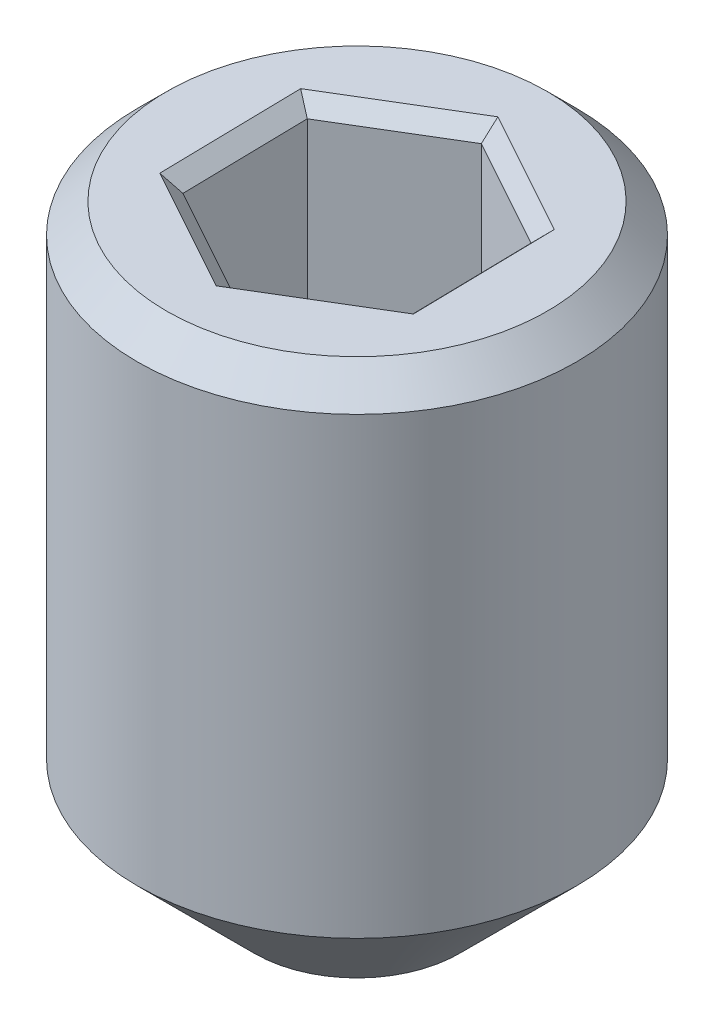
from build123d import *

# Parameters (mm, degrees)
SKETCH1_R           = 1.5
BOSS_EXTRUDE1_DEPTH = 4.1
CUT_EXTRUDE2_DEPTH  = 2
CHAMFER1_SIZE       = 0.2
CHAMFER2_SIZE       = 0.1
FILLET3_R           = 0.6
CHAMFER3_SIZE       = 0.8


with BuildPart() as part:
    # Sketch1 → Boss-Extrude1 (new body)
    with BuildSketch(Plane(origin=(0, 0, 0), x_dir=(1, 0, 0), z_dir=(0, 1, 0))):
        Circle(SKETCH1_R)
    extrude(amount=BOSS_EXTRUDE1_DEPTH)

    # Sketch2 → Cut-Extrude2 (cut)
    with BuildSketch(Plane(origin=(0, 4.1, 0), x_dir=(1, 0, 0), z_dir=(0, 1, 0))):
        Polygon((0.758195887, -0.418496113), (0.741526209, 0.447368843), (-0.016669678, 0.865864956), (-0.758195887, 0.418496113), (-0.741526209, -0.447368843), (0.016669678, -0.865864956), align=None)
    extrude(amount=-CUT_EXTRUDE2_DEPTH, mode=Mode.SUBTRACT)

    # Chamfer1
    chamfer1_edges = [part.edges().sort_by_distance(p)[0] for p in [
        (-1.5, 4.1, 0),
    ]]
    chamfer(chamfer1_edges, length=CHAMFER1_SIZE)

    # Chamfer2
    chamfer2_edges = [part.edges().sort_by_distance(p)[0] for p in [
        (0.387432783, 4.1, 0.642180535),
        (0.749861048, 4.1, -0.014436365),
        (0.362428265, 4.1, -0.656616899),
        (-0.387432783, 4.1, -0.642180535),
        (-0.749861048, 4.1, 0.014436365),
        (-0.362428265, 4.1, 0.656616899),
    ]]
    chamfer(chamfer2_edges, length=CHAMFER2_SIZE)

    # Fillet3
    fillet3_edges = [part.edges().sort_by_distance(p)[0] for p in [
        (0.749861048, 2.1, -0.014436365),
        (0.387432783, 2.1, 0.642180535),
        (-0.362428265, 2.1, 0.656616899),
        (-0.749861048, 2.1, 0.014436365),
        (-0.387432783, 2.1, -0.642180535),
        (0.362428265, 2.1, -0.656616899),
    ]]
    fillet(fillet3_edges, radius=FILLET3_R)

    # Chamfer3
    chamfer3_edges = [part.edges().sort_by_distance(p)[0] for p in [
        (-1.5, 0, 0),
    ]]
    chamfer(chamfer3_edges, length=CHAMFER3_SIZE)


solid = part.part
